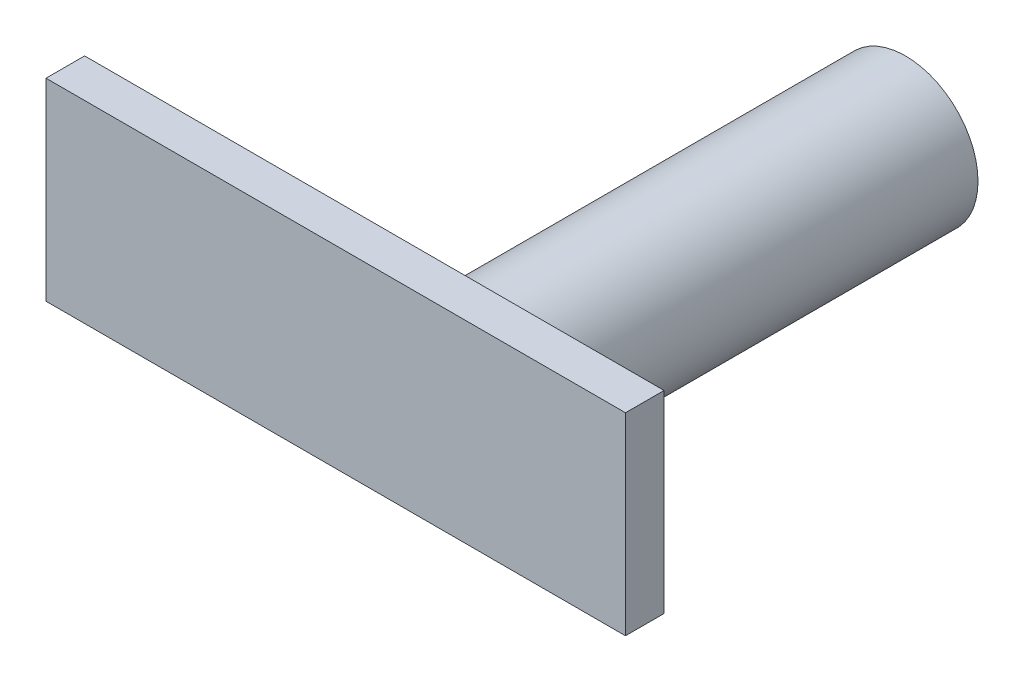
from build123d import *

# Parameters (mm, degrees)
SKETCH4_W           = 6
SKETCH4_H           = 2
BOSS_EXTRUDE3_DEPTH = 0.4
SKETCH6_R           = 0.75
BOSS_EXTRUDE4_DEPTH = 4.5


with BuildPart() as part:
    # Sketch4 → Boss-Extrude3 (new body)
    with BuildSketch(Plane.XY.offset(5)):
        with Locations((-1, 0)):
            Rectangle(SKETCH4_W, SKETCH4_H)
    extrude(amount=BOSS_EXTRUDE3_DEPTH)

    # Sketch6 → Boss-Extrude4 (add)
    with BuildSketch(Plane.XY.offset(5)):
        Circle(SKETCH6_R)
    extrude(amount=-BOSS_EXTRUDE4_DEPTH)


solid = part.part
